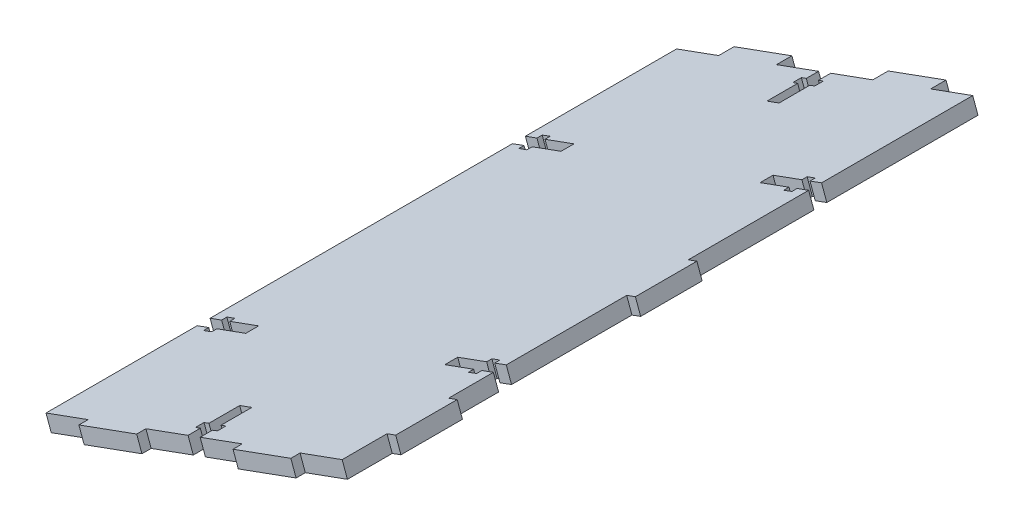
from build123d import *

# Parameters (mm, degrees)
BOSS_EXTRUDE1_DEPTH = 205
CUT_EXTRUDE3_DEPTH  = 38.907676661
SKETCH5_W           = 20
SKETCH5_H           = 5
SKETCH5_W_2         = 3
SKETCH5_H_2         = 20
SKETCH5_H_3         = 3
BOSS_EXTRUDE2_DEPTH = 5


with BuildPart() as part:
    # Sketch2 → Boss-Extrude1 (new body)
    with BuildSketch(Plane.XY.offset(14.2)):
        Polygon((-52.961538618, -36.862052104), (-51.252736373, -41.56098761), (-147.541457764, -76.577085001), (-149.250260009, -71.878149495), align=None)
    extrude(amount=BOSS_EXTRUDE1_DEPTH)

    # Sketch4 → Cut-Extrude3 (cut, through all)
    with BuildSketch(Plane(origin=(7.362313595, -20.245196221, 0), x_dir=(-0.939787101, -0.341760449, 0), z_dir=(0.341760449, -0.939787101, 0))):
        Polygon((111.499570088, -14.2), (115.699570088, -14.2), (115.699570088, -18.2), (117.399570088, -18.2), (117.399570088, -21), (115.699570088, -21), (115.699570088, -31), (111.499570088, -31), (111.499570088, -21), (109.799570088, -21), (109.799570088, -18.2), (111.499570088, -18.2), align=None)
        Polygon((62.37056233, -67.55), (62.37056233, -63.35), (66.37056233, -63.35), (66.37056233, -61.65), (69.17056233, -61.65), (69.17056233, -63.35), (79.17056233, -63.35), (79.17056233, -67.55), (69.17056233, -67.55), (69.17056233, -69.25), (66.37056233, -69.25), (66.37056233, -67.55), align=None)
        Polygon((115.699570088, -219.2), (111.499570088, -219.2), (111.499570088, -215.2), (109.799570088, -215.2), (109.799570088, -212.4), (111.499570088, -212.4), (111.499570088, -202.4), (115.699570088, -202.4), (115.699570088, -212.4), (117.399570088, -212.4), (117.399570088, -215.2), (115.699570088, -215.2), align=None)
        Polygon((66.37056233, -170.05), (66.37056233, -171.75), (69.17056233, -171.75), (69.17056233, -170.05), (79.17056233, -170.05), (79.17056233, -165.85), (69.17056233, -165.85), (69.17056233, -164.15), (66.37056233, -164.15), (66.37056233, -165.85), (62.37056233, -165.85), (62.37056233, -170.05), align=None)
        Polygon((164.828577846, -165.85), (164.828577846, -170.05), (160.828577846, -170.05), (160.828577846, -171.75), (158.028577846, -171.75), (158.028577846, -170.05), (148.028577846, -170.05), (148.028577846, -165.85), (158.028577846, -165.85), (158.028577846, -164.15), (160.828577846, -164.15), (160.828577846, -165.85), align=None)
        Polygon((160.828577846, -63.35), (160.828577846, -61.65), (158.028577846, -61.65), (158.028577846, -63.35), (148.028577846, -63.35), (148.028577846, -67.55), (158.028577846, -67.55), (158.028577846, -69.25), (160.828577846, -69.25), (160.828577846, -67.55), (164.828577846, -67.55), (164.828577846, -63.35), align=None)
    extrude(amount=-CUT_EXTRUDE3_DEPTH, mode=Mode.SUBTRACT)

    # Sketch5 → Boss-Extrude2 (add)
    with BuildSketch(Plane(origin=(7.362313595, -20.245196221, 0), x_dir=(0.939787101, 0.341760449, 0), z_dir=(0.341760449, -0.939787101, 0))):
        with Locations((-86.935066209, 11.7)):
            Rectangle(SKETCH5_W, SKETCH5_H)
        with Locations((-140.264073967, 11.7)):
            Rectangle(SKETCH5_W, SKETCH5_H)
        with Locations((-60.87056233, 116.7)):
            Rectangle(SKETCH5_W_2, SKETCH5_H_2)
        with Locations((-60.87056233, 194.625)):
            Rectangle(SKETCH5_W_2, SKETCH5_H_2)
        with Locations((-86.935066209, 220.7)):
            Rectangle(SKETCH5_W, SKETCH5_H_3)
        with Locations((-140.264073967, 220.7)):
            Rectangle(SKETCH5_W, SKETCH5_H_3)
    extrude(amount=-BOSS_EXTRUDE2_DEPTH)


solid = part.part
